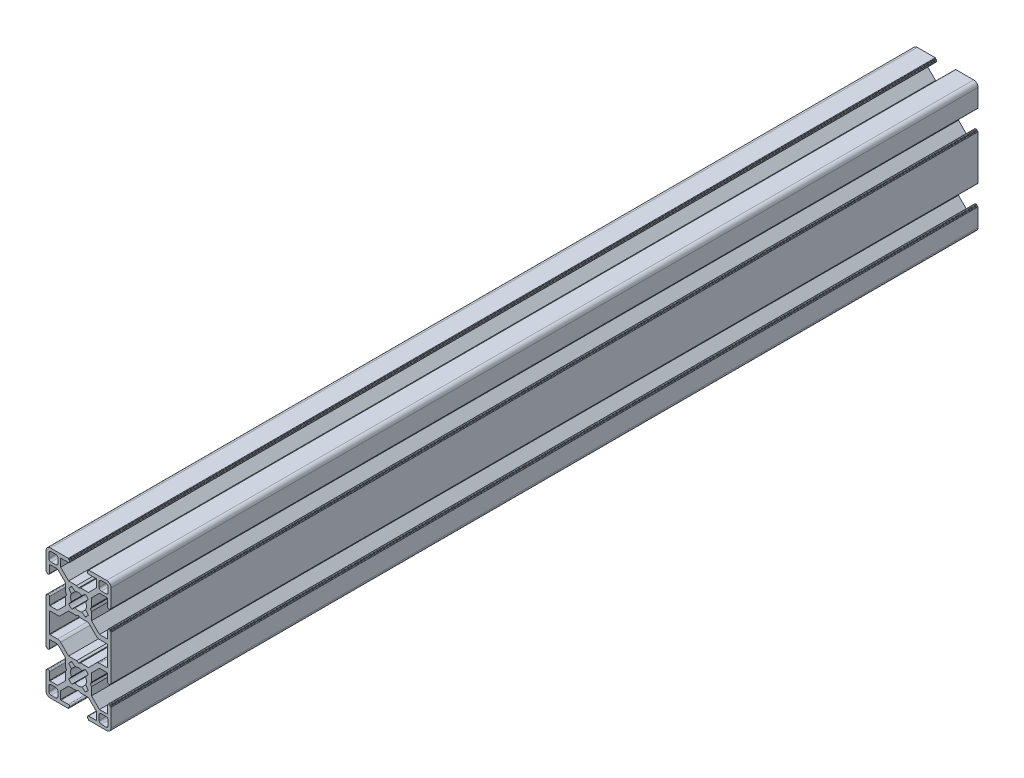
from build123d import *

# Parameters (mm, degrees)
EXTRUDE_1_DEPTH = 400


with BuildPart() as part:
    # Эскиз1 → Бобышка-Вытянуть1 (new body)
    with BuildSketch(Plane.XY):
        with BuildLine():
            Line((5.752168384, -0.968649296), (5.232566967, -1.868660602))
            Line((5.232566967, -1.868660602), (5.752168384, -2.768671908))
            Line((5.752168384, -2.768671908), (5.752180233, -6.45891247))
            Line((5.752180233, -6.45891247), (9.411928364, -10.118660601))
            Line((9.411928364, -10.118660601), (12.897714803, -10.118660601))
            ThreePointArc((12.897714803, -10.118660601), (13.039136159, -10.060081958), (13.097714802, -9.918660601))
            Line((13.097714802, -9.918660601), (13.097714802, -6.518659839))
            ThreePointArc((13.097714802, -6.518659839), (13.273450733, -6.09439577), (13.697714802, -5.918659839))
            Line((13.697714802, -5.918659839), (14.047714845, -5.918659839))
            ThreePointArc((14.047714845, -5.918659839), (14.189136403, -5.977238566), (14.24771513, -6.118660123))
            Line((14.24771513, -6.118660123), (14.24771513, -6.218659555))
            ThreePointArc((14.24771513, -6.218659555), (14.306293857, -6.360081112), (14.447715414, -6.418659839))
            Line((14.447715414, -6.418659839), (14.547714518, -6.418659839))
            ThreePointArc((14.547714518, -6.418659839), (14.689136075, -6.477238566), (14.747714802, -6.618660123))
            Line((14.747714802, -6.618660123), (14.747714802, -27.118661081))
            ThreePointArc((14.747714802, -27.118661081), (14.689136076, -27.260082638), (14.547714518, -27.318661365))
            Line((14.547714518, -27.318661365), (14.447715414, -27.318661365))
            ThreePointArc((14.447715414, -27.318661365), (14.306293857, -27.377240092), (14.24771513, -27.51866165))
            Line((14.24771513, -27.51866165), (14.24771513, -27.618661081))
            ThreePointArc((14.24771513, -27.618661081), (14.189136403, -27.760082638), (14.047714845, -27.818661365))
            Line((14.047714845, -27.818661365), (13.697714802, -27.818661365))
            ThreePointArc((13.697714802, -27.818661365), (13.273450733, -27.642925434), (13.097714802, -27.218661365))
            Line((13.097714802, -27.218661365), (13.097714802, -23.818660603))
            ThreePointArc((13.097714802, -23.818660603), (13.039136158, -23.677239247), (12.897714802, -23.618660603))
            Line((12.897714802, -23.618660603), (9.411928364, -23.618660603))
            Line((9.411928364, -23.618660603), (5.752180232, -27.278408735))
            Line((5.752180232, -27.278408735), (5.752168383, -30.968649297))
            Line((5.752168383, -30.968649297), (5.232566966, -31.868660603))
            Line((5.232566966, -31.868660603), (5.752168383, -32.768671908))
            Line((5.752168383, -32.768671908), (5.752168383, -36.458900622))
            Line((5.752168383, -36.458900622), (9.411941506, -40.118673744))
            Line((9.411941506, -40.118673744), (12.897714802, -40.118660603))
            ThreePointArc((12.897714802, -40.118660603), (13.039136158, -40.060081959), (13.097714802, -39.918660603))
            Line((13.097714802, -39.918660603), (13.097714802, -36.51865984))
            ThreePointArc((13.097714802, -36.51865984), (13.273450733, -36.094395771), (13.697714802, -35.91865984))
            Line((13.697714802, -35.91865984), (14.047714845, -35.91865984))
            ThreePointArc((14.047714845, -35.91865984), (14.189136402, -35.977238567), (14.247715129, -36.118660124))
            Line((14.247715129, -36.118660124), (14.247715129, -36.218659555))
            ThreePointArc((14.247715129, -36.218659555), (14.306293856, -36.360081113), (14.447715413, -36.41865984))
            Line((14.447715413, -36.41865984), (14.547714518, -36.41865984))
            ThreePointArc((14.547714518, -36.41865984), (14.689136075, -36.477238567), (14.747714802, -36.618660124))
            Line((14.747714802, -36.618660124), (14.747714802, -44.868660949))
            ThreePointArc((14.747714802, -44.868660949), (14.161928465, -46.282874266), (12.747715148, -46.868660603))
            Line((12.747715148, -46.868660603), (4.497714747, -46.868660603))
            ThreePointArc((4.497714747, -46.868660603), (4.356293121, -46.810081847), (4.297714366, -46.668660221))
            Line((4.297714366, -46.668660221), (4.297714366, -46.568660022))
            ThreePointArc((4.297714366, -46.568660022), (4.239135892, -46.427239076), (4.097714946, -46.368660603))
            Line((4.097714946, -46.368660603), (3.997715175, -46.368660603))
            ThreePointArc((3.997715175, -46.368660603), (3.856293555, -46.310081849), (3.797714802, -46.168660229))
            Line((3.797714802, -46.168660229), (3.797714802, -45.818660603))
            ThreePointArc((3.797714802, -45.818660603), (3.973450733, -45.394396534), (4.397714802, -45.218660603))
            Line((4.397714802, -45.218660603), (7.797714802, -45.218660603))
            ThreePointArc((7.797714802, -45.218660603), (7.939136158, -45.160081959), (7.997714802, -45.018660603))
            Line((7.997714802, -45.018660603), (7.997714802, -41.532874164))
            Line((7.997714802, -41.532874164), (4.33350124, -37.868660603))
            Line((4.33350124, -37.868660603), (0.647714748, -37.868660603))
            Line((0.647714748, -37.868660603), (-0.252285198, -37.35351244))
            Line((-0.252285198, -37.35351244), (-1.152285143, -37.868660603))
            Line((-1.152285143, -37.868660603), (-4.838071635, -37.868660603))
            Line((-4.838071635, -37.868660603), (-8.502285197, -41.532874164))
            Line((-8.502285197, -41.532874164), (-8.502285197, -45.018660603))
            ThreePointArc((-8.502285197, -45.018660603), (-8.443706553, -45.160081959), (-8.302285197, -45.218660603))
            Line((-8.302285197, -45.218660603), (-4.902285197, -45.218660603))
            ThreePointArc((-4.902285197, -45.218660603), (-4.478021128, -45.394396534), (-4.302285197, -45.818660603))
            Line((-4.302285197, -45.818660603), (-4.302285197, -46.168660229))
            ThreePointArc((-4.302285197, -46.168660229), (-4.36086395, -46.310081849), (-4.50228557, -46.368660603))
            Line((-4.50228557, -46.368660603), (-4.602285341, -46.368660603))
            ThreePointArc((-4.602285341, -46.368660603), (-4.743706287, -46.427239076), (-4.802284761, -46.568660022))
            Line((-4.802284761, -46.568660022), (-4.802284761, -46.668660221))
            ThreePointArc((-4.802284761, -46.668660221), (-4.860863516, -46.810081847), (-5.002285142, -46.868660603))
            Line((-5.002285142, -46.868660603), (-13.252285543, -46.868660603))
            ThreePointArc((-13.252285543, -46.868660603), (-14.666498861, -46.282874266), (-15.252285197, -44.868660949))
            Line((-15.252285197, -44.868660949), (-15.252285197, -36.618660124))
            ThreePointArc((-15.252285197, -36.618660124), (-15.19370647, -36.477238567), (-15.052284913, -36.41865984))
            Line((-15.052284913, -36.41865984), (-14.952285808, -36.41865984))
            ThreePointArc((-14.952285808, -36.41865984), (-14.810864251, -36.360081113), (-14.752285524, -36.218659555))
            Line((-14.752285524, -36.218659555), (-14.752285524, -36.118660124))
            ThreePointArc((-14.752285524, -36.118660124), (-14.693706797, -35.977238567), (-14.55228524, -35.91865984))
            Line((-14.55228524, -35.91865984), (-14.202285197, -35.91865984))
            ThreePointArc((-14.202285197, -35.91865984), (-13.778021128, -36.094395771), (-13.602285197, -36.51865984))
            Line((-13.602285197, -36.51865984), (-13.602285197, -39.918660603))
            ThreePointArc((-13.602285197, -39.918660603), (-13.543706553, -40.060081959), (-13.402285197, -40.118660603))
            Line((-13.402285197, -40.118660603), (-9.916498759, -40.118660603))
            Line((-9.916498759, -40.118660603), (-6.256750627, -36.45891247))
            Line((-6.256750627, -36.45891247), (-6.256738778, -32.768671908))
            Line((-6.256738778, -32.768671908), (-5.737137361, -31.868660603))
            Line((-5.737137361, -31.868660603), (-6.256738778, -30.968649297))
            Line((-6.256738778, -30.968649297), (-6.256750627, -27.278408735))
            Line((-6.256750627, -27.278408735), (-9.916498759, -23.618660602))
            Line((-9.916498759, -23.618660602), (-13.402285197, -23.618660602))
            ThreePointArc((-13.402285197, -23.618660602), (-13.543706553, -23.677239246), (-13.602285197, -23.818660602))
            Line((-13.602285197, -23.818660602), (-13.602285197, -27.218661365))
            ThreePointArc((-13.602285197, -27.218661365), (-13.778021128, -27.642925433), (-14.202285197, -27.818661365))
            Line((-14.202285197, -27.818661365), (-14.55228524, -27.818661365))
            ThreePointArc((-14.55228524, -27.818661365), (-14.693706798, -27.760082638), (-14.752285525, -27.618661081))
            Line((-14.752285525, -27.618661081), (-14.752285525, -27.518661649))
            ThreePointArc((-14.752285525, -27.518661649), (-14.810864252, -27.377240092), (-14.952285809, -27.318661365))
            Line((-14.952285809, -27.318661365), (-15.052284913, -27.318661365))
            ThreePointArc((-15.052284913, -27.318661365), (-15.193706471, -27.260082638), (-15.252285198, -27.118661081))
            Line((-15.252285198, -27.118661081), (-15.252285198, -6.618660123))
            ThreePointArc((-15.252285198, -6.618660123), (-15.193706471, -6.477238566), (-15.052284913, -6.418659839))
            Line((-15.052284913, -6.418659839), (-14.952285809, -6.418659839))
            ThreePointArc((-14.952285809, -6.418659839), (-14.810864252, -6.360081112), (-14.752285525, -6.218659555))
            Line((-14.752285525, -6.218659555), (-14.752285525, -6.118660123))
            ThreePointArc((-14.752285525, -6.118660123), (-14.693706798, -5.977238566), (-14.55228524, -5.918659839))
            Line((-14.55228524, -5.918659839), (-14.202285197, -5.918659839))
            ThreePointArc((-14.202285197, -5.918659839), (-13.778021128, -6.09439577), (-13.602285197, -6.518659839))
            Line((-13.602285197, -6.518659839), (-13.602285198, -9.918660601))
            ThreePointArc((-13.602285198, -9.918660601), (-13.543706554, -10.060081958), (-13.402285198, -10.118660601))
            Line((-13.402285198, -10.118660601), (-9.91649876, -10.118660602))
            Line((-9.91649876, -10.118660602), (-6.256750628, -6.45891247))
            Line((-6.256750628, -6.45891247), (-6.256738779, -2.768671908))
            Line((-6.256738779, -2.768671908), (-5.737137362, -1.868660602))
            Line((-5.737137362, -1.868660602), (-6.256738779, -0.968649296))
            Line((-6.256738779, -0.968649296), (-6.256750628, 2.721591266))
            Line((-6.256750628, 2.721591266), (-9.91649876, 6.381339399))
            Line((-9.91649876, 6.381339399), (-13.402285198, 6.381339399))
            ThreePointArc((-13.402285198, 6.381339399), (-13.543706554, 6.322760755), (-13.602285198, 6.181339399))
            Line((-13.602285198, 6.181339399), (-13.602285198, 2.781338635))
            ThreePointArc((-13.602285198, 2.781338635), (-13.778021129, 2.357074567), (-14.202285198, 2.181338635))
            Line((-14.202285198, 2.181338635), (-14.55228524, 2.181338635))
            ThreePointArc((-14.55228524, 2.181338635), (-14.693706798, 2.239917362), (-14.752285525, 2.381338919))
            Line((-14.752285525, 2.381338919), (-14.752285525, 2.481338351))
            ThreePointArc((-14.752285525, 2.481338351), (-14.810864252, 2.622759908), (-14.952285809, 2.681338635))
            Line((-14.952285809, 2.681338635), (-15.052284913, 2.681338635))
            ThreePointArc((-15.052284913, 2.681338635), (-15.193706471, 2.739917362), (-15.252285198, 2.881338919))
            Line((-15.252285198, 2.881338919), (-15.252285198, 11.131339744))
            ThreePointArc((-15.252285198, 11.131339744), (-14.666498861, 12.545553062), (-13.252285544, 13.131339398))
            Line((-13.252285544, 13.131339398), (-5.002285143, 13.131339398))
            ThreePointArc((-5.002285143, 13.131339398), (-4.860863517, 13.072760643), (-4.802284762, 12.931339017))
            Line((-4.802284762, 12.931339017), (-4.802284762, 12.831338818))
            ThreePointArc((-4.802284762, 12.831338818), (-4.743706288, 12.689917872), (-4.602285342, 12.631339398))
            Line((-4.602285342, 12.631339398), (-4.502285571, 12.631339398))
            ThreePointArc((-4.502285571, 12.631339398), (-4.360863951, 12.572760645), (-4.302285198, 12.431339025))
            Line((-4.302285198, 12.431339025), (-4.302285198, 12.081339398))
            ThreePointArc((-4.302285198, 12.081339398), (-4.478021129, 11.657075329), (-4.902285198, 11.481339398))
            Line((-4.902285198, 11.481339398), (-8.302285197, 11.481339398))
            ThreePointArc((-8.302285197, 11.481339398), (-8.443706553, 11.422760754), (-8.502285197, 11.281339398))
            Line((-8.502285197, 11.281339398), (-8.502285197, 7.79555296))
            Line((-8.502285197, 7.79555296), (-4.838071635, 4.131339398))
            Line((-4.838071635, 4.131339398), (-1.152285143, 4.131339398))
            Line((-1.152285143, 4.131339398), (-0.252285198, 3.616191235))
            Line((-0.252285198, 3.616191235), (0.647714748, 4.131339398))
            Line((0.647714748, 4.131339398), (4.33350124, 4.131339398))
            Line((4.33350124, 4.131339398), (7.997714802, 7.79555296))
            Line((7.997714802, 7.79555296), (7.997714802, 11.281339398))
            ThreePointArc((7.997714802, 11.281339398), (7.939136158, 11.422760754), (7.797714802, 11.481339398))
            Line((7.797714802, 11.481339398), (4.397714802, 11.481339398))
            ThreePointArc((4.397714802, 11.481339398), (3.973450734, 11.657075329), (3.797714802, 12.081339398))
            Line((3.797714802, 12.081339398), (3.797714802, 12.431339025))
            ThreePointArc((3.797714802, 12.431339025), (3.856293556, 12.572760645), (3.997715176, 12.631339398))
            Line((3.997715176, 12.631339398), (4.097714947, 12.631339398))
            ThreePointArc((4.097714947, 12.631339398), (4.239135893, 12.689917872), (4.297714367, 12.831338818))
            Line((4.297714367, 12.831338818), (4.297714367, 12.931339017))
            ThreePointArc((4.297714367, 12.931339017), (4.356293122, 13.072760643), (4.497714748, 13.131339398))
            Line((4.497714748, 13.131339398), (12.747715149, 13.131339398))
            ThreePointArc((12.747715149, 13.131339398), (14.161928466, 12.545553062), (14.747714802, 11.131339744))
            Line((14.747714802, 11.131339744), (14.747714802, 2.881338919))
            ThreePointArc((14.747714802, 2.881338919), (14.689136075, 2.739917362), (14.547714518, 2.681338635))
            Line((14.547714518, 2.681338635), (14.447715414, 2.681338635))
            ThreePointArc((14.447715414, 2.681338635), (14.306293857, 2.622759908), (14.24771513, 2.481338351))
            Line((14.24771513, 2.481338351), (14.24771513, 2.381338919))
            ThreePointArc((14.24771513, 2.381338919), (14.189136403, 2.239917362), (14.047714845, 2.181338635))
            Line((14.047714845, 2.181338635), (13.697714802, 2.181338635))
            ThreePointArc((13.697714802, 2.181338635), (13.273450734, 2.357074567), (13.097714802, 2.781338635))
            Line((13.097714802, 2.781338635), (13.097714802, 6.181339399))
            ThreePointArc((13.097714802, 6.181339399), (13.039136159, 6.322760755), (12.897714802, 6.381339399))
            Line((12.897714802, 6.381339399), (9.411941507, 6.38135254))
            Line((9.411941507, 6.38135254), (5.752168384, 2.721579417))
            Line((5.752168384, 2.721579417), (5.752168384, -0.968649296))
        make_face()
        with BuildLine():
            Line((13.447715893, 10.831339806), (13.447715893, 8.631339024))
            ThreePointArc((13.447715893, 8.631339024), (13.154822677, 7.92423225), (12.447715902, 7.631339034))
            Line((12.447715902, 7.631339034), (10.24771513, 7.631339034))
            ThreePointArc((10.24771513, 7.631339034), (9.540608346, 7.92423225), (9.24771513, 8.631339034))
            Line((9.24771513, 8.631339034), (9.24771513, 10.831339797))
            ThreePointArc((9.24771513, 10.831339797), (9.540608346, 11.538446581), (10.24771513, 11.831339797))
            Line((10.24771513, 11.831339797), (12.447715902, 11.831339797))
            ThreePointArc((12.447715902, 11.831339797), (13.154822677, 11.538446581), (13.447715893, 10.831339806))
        make_face(mode=Mode.SUBTRACT)
        with BuildLine():
            Line((2.883644214, 2.649740301), (1.347844326, 1.411901165))
            ThreePointArc((1.347844326, 1.411901165), (-0.252285198, 1.781339398), (-1.852414721, 1.411901165))
            Line((-1.852414721, 1.411901165), (-3.38821461, 2.649740301))
            ThreePointArc((-3.38821461, 2.649740301), (-4.133287457, 2.028494959), (-4.75762209, 1.286008871))
            Line((-4.75762209, 1.286008871), (-3.532846929, -0.268531005))
            ThreePointArc((-3.532846929, -0.268531005), (-3.902285198, -1.868660602), (-3.532846929, -3.468790198))
            Line((-3.532846929, -3.468790198), (-4.75762209, -5.023330075))
            ThreePointArc((-4.75762209, -5.023330075), (-4.133287457, -5.765816162), (-3.38821461, -6.387061505))
            Line((-3.38821461, -6.387061505), (-1.852414721, -5.149222369))
            ThreePointArc((-1.852414721, -5.149222369), (-0.252285198, -5.518660602), (1.347844326, -5.149222369))
            Line((1.347844326, -5.149222369), (2.883644214, -6.387061505))
            ThreePointArc((2.883644214, -6.387061505), (3.628717062, -5.765816162), (4.253051695, -5.023330075))
            Line((4.253051695, -5.023330075), (3.028276534, -3.468790198))
            ThreePointArc((3.028276534, -3.468790198), (3.397714802, -1.868660602), (3.028276534, -0.268531005))
            Line((3.028276534, -0.268531005), (4.253051695, 1.286008871))
            ThreePointArc((4.253051695, 1.286008871), (3.628717062, 2.028494959), (2.883644214, 2.649740301))
        make_face(mode=Mode.SUBTRACT)
        with BuildLine():
            Line((-0.252285198, -7.353512439), (0.647714748, -7.868660602))
            Line((0.647714748, -7.868660602), (4.33350124, -7.868660602))
            Line((4.33350124, -7.868660602), (7.997714802, -11.532874164))
            ThreePointArc((7.997714802, -11.532874164), (8.6465615, -11.966419666), (9.411928364, -12.118660601))
            Line((9.411928364, -12.118660601), (12.897714803, -12.118660601))
            ThreePointArc((12.897714803, -12.118660601), (13.039136159, -12.177239245), (13.097714803, -12.318660601))
            Line((13.097714803, -12.318660601), (13.097714805, -21.418660602))
            ThreePointArc((13.097714805, -21.418660602), (13.039136161, -21.560081958), (12.897714805, -21.618660602))
            Line((12.897714805, -21.618660602), (9.411928364, -21.618660602))
            ThreePointArc((9.411928364, -21.618660602), (8.6465615, -21.770901537), (7.997714802, -22.20444704))
            Line((7.997714802, -22.20444704), (4.33350124, -25.868660602))
            Line((4.33350124, -25.868660602), (0.647714748, -25.868660602))
            Line((0.647714748, -25.868660602), (-0.252285198, -26.383808765))
            Line((-0.252285198, -26.383808765), (-1.152285143, -25.868660602))
            Line((-1.152285143, -25.868660602), (-4.838071635, -25.868660602))
            Line((-4.838071635, -25.868660602), (-8.502285197, -22.20444704))
            ThreePointArc((-8.502285197, -22.20444704), (-9.151131895, -21.770901537), (-9.916498759, -21.618660602))
            Line((-9.916498759, -21.618660602), (-13.4022852, -21.618660602))
            ThreePointArc((-13.4022852, -21.618660602), (-13.543706556, -21.560081958), (-13.6022852, -21.418660602))
            Line((-13.6022852, -21.418660602), (-13.602285198, -12.318660601))
            ThreePointArc((-13.602285198, -12.318660601), (-13.543706554, -12.177239245), (-13.402285198, -12.118660601))
            Line((-13.402285198, -12.118660601), (-9.916498759, -12.118660601))
            ThreePointArc((-9.916498759, -12.118660601), (-9.151131895, -11.966419666), (-8.502285197, -11.532874164))
            Line((-8.502285197, -11.532874164), (-4.838071635, -7.868660602))
            Line((-4.838071635, -7.868660602), (-1.152285143, -7.868660602))
            Line((-1.152285143, -7.868660602), (-0.252285198, -7.353512439))
        make_face(mode=Mode.SUBTRACT)
        with BuildLine():
            Line((-10.752285525, 11.831339797), (-12.952286297, 11.831339797))
            ThreePointArc((-12.952286297, 11.831339797), (-13.659393072, 11.538446581), (-13.952286288, 10.831339806))
            Line((-13.952286288, 10.831339806), (-13.952286288, 8.631339024))
            ThreePointArc((-13.952286288, 8.631339024), (-13.659393072, 7.92423225), (-12.952286297, 7.631339034))
            Line((-12.952286297, 7.631339034), (-10.752285525, 7.631339034))
            ThreePointArc((-10.752285525, 7.631339034), (-10.045178741, 7.92423225), (-9.752285525, 8.631339034))
            Line((-9.752285525, 8.631339034), (-9.752285525, 10.831339797))
            ThreePointArc((-9.752285525, 10.831339797), (-10.045178741, 11.538446581), (-10.752285525, 11.831339797))
        make_face(mode=Mode.SUBTRACT)
        with BuildLine():
            Line((-13.952286288, -44.568661), (-13.952286288, -42.368660237))
            ThreePointArc((-13.952286288, -42.368660237), (-13.659393072, -41.661553453), (-12.952286288, -41.368660237))
            Line((-12.952286288, -41.368660237), (-10.752285525, -41.368660237))
            ThreePointArc((-10.752285525, -41.368660237), (-10.045178741, -41.661553453), (-9.752285525, -42.368660237))
            Line((-9.752285525, -42.368660237), (-9.752285525, -44.568661))
            ThreePointArc((-9.752285525, -44.568661), (-10.045178741, -45.275767784), (-10.752285525, -45.568661))
            Line((-10.752285525, -45.568661), (-12.952286288, -45.568661))
            ThreePointArc((-12.952286288, -45.568661), (-13.659393072, -45.275767784), (-13.952286288, -44.568661))
        make_face(mode=Mode.SUBTRACT)
        with BuildLine():
            Line((-3.38821461, -36.387061505), (-1.852414721, -35.149222369))
            ThreePointArc((-1.852414721, -35.149222369), (-0.252285198, -35.518660602), (1.347844326, -35.149222369))
            Line((1.347844326, -35.149222369), (2.883644214, -36.387061505))
            ThreePointArc((2.883644214, -36.387061505), (3.628717062, -35.765816162), (4.253051695, -35.023330075))
            Line((4.253051695, -35.023330075), (3.028276534, -33.468790198))
            ThreePointArc((3.028276534, -33.468790198), (3.397714802, -31.868660602), (3.028276534, -30.268531005))
            Line((3.028276534, -30.268531005), (4.253051695, -28.713991129))
            ThreePointArc((4.253051695, -28.713991129), (3.628717062, -27.971505041), (2.883644214, -27.350259699))
            Line((2.883644214, -27.350259699), (1.347844326, -28.588098835))
            ThreePointArc((1.347844326, -28.588098835), (-0.252285198, -28.218660602), (-1.852414721, -28.588098835))
            Line((-1.852414721, -28.588098835), (-3.38821461, -27.350259699))
            ThreePointArc((-3.38821461, -27.350259699), (-4.133287457, -27.971505041), (-4.75762209, -28.713991129))
            Line((-4.75762209, -28.713991129), (-3.532846929, -30.268531005))
            ThreePointArc((-3.532846929, -30.268531005), (-3.902285198, -31.868660602), (-3.532846929, -33.468790198))
            Line((-3.532846929, -33.468790198), (-4.75762209, -35.023330075))
            ThreePointArc((-4.75762209, -35.023330075), (-4.133287457, -35.765816162), (-3.38821461, -36.387061505))
        make_face(mode=Mode.SUBTRACT)
        with BuildLine():
            Line((10.24771513, -45.568661), (12.447715893, -45.568661))
            ThreePointArc((12.447715893, -45.568661), (13.154822677, -45.275767784), (13.447715893, -44.568661))
            Line((13.447715893, -44.568661), (13.447715893, -42.368660237))
            ThreePointArc((13.447715893, -42.368660237), (13.154822677, -41.661553453), (12.447715893, -41.368660237))
            Line((12.447715893, -41.368660237), (10.24771513, -41.368660237))
            ThreePointArc((10.24771513, -41.368660237), (9.540608346, -41.661553453), (9.24771513, -42.368660237))
            Line((9.24771513, -42.368660237), (9.24771513, -44.568661))
            ThreePointArc((9.24771513, -44.568661), (9.540608346, -45.275767784), (10.24771513, -45.568661))
        make_face(mode=Mode.SUBTRACT)
    extrude(amount=EXTRUDE_1_DEPTH)


solid = part.part
